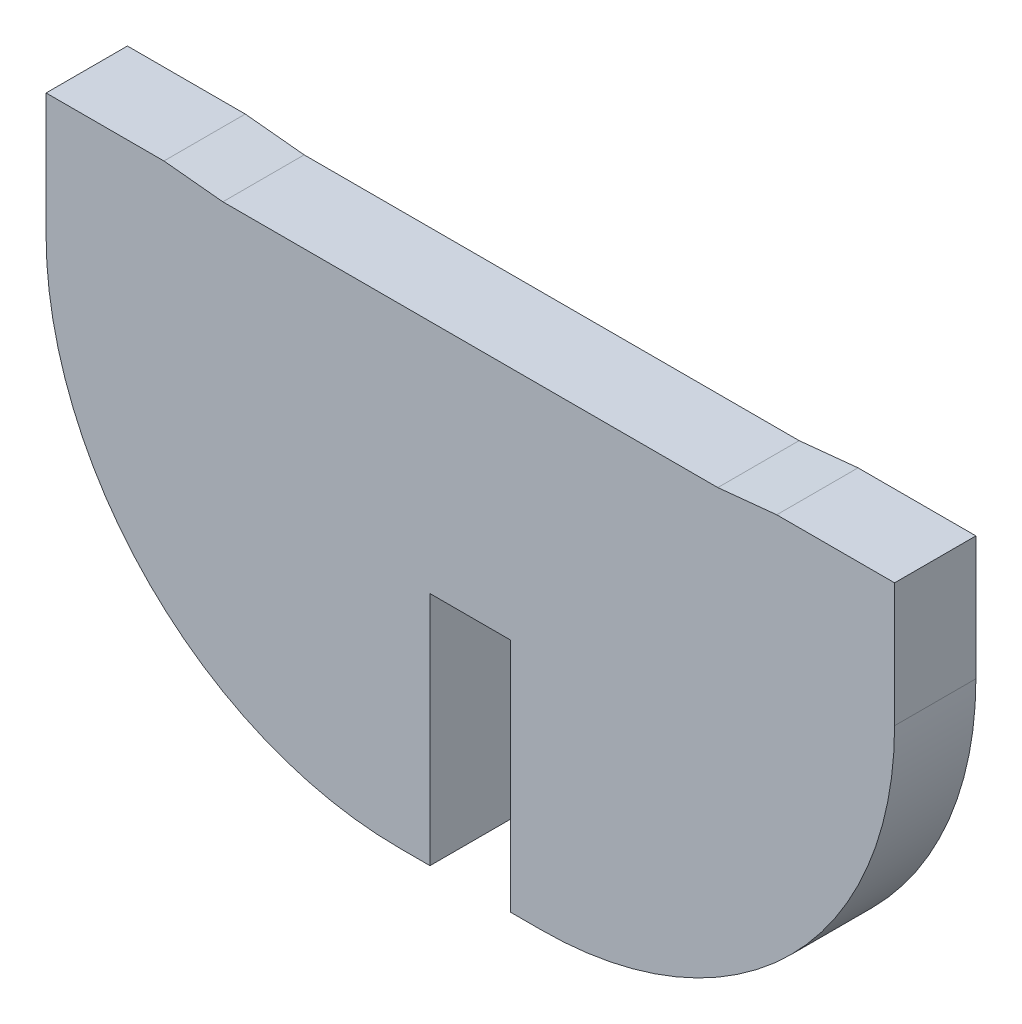
from build123d import *

# Parameters (mm, degrees)
SKETCH1_W           = 72
SKETCH1_H           = 40
BOSS_EXTRUDE1_DEPTH = 6.9
SKETCH2_W           = 6.85
SKETCH2_H           = 40
CUT_EXTRUDE1_DEPTH  = 7.9
FILLET1_R           = 30
BOSS_EXTRUDE2_DEPTH = 6.9


with BuildPart() as part:
    # Sketch1 → Boss-Extrude1 (new body)
    with BuildSketch(Plane.XY):
        Rectangle(SKETCH1_W, SKETCH1_H)
    extrude(amount=BOSS_EXTRUDE1_DEPTH)

    # Sketch2 → Cut-Extrude1 (cut, through all)
    with BuildSketch(Plane.XY.offset(6.9)):
        with Locations((0, -20)):
            Rectangle(SKETCH2_W, SKETCH2_H)
    extrude(amount=-CUT_EXTRUDE1_DEPTH, mode=Mode.SUBTRACT)

    # Fillet1
    fillet1_edges = [part.edges().sort_by_distance(p)[0] for p in [
        (36, -20, 3.45),
        (-36, -20, 3.45),
    ]]
    fillet(fillet1_edges, radius=FILLET1_R)

    # Sketch3 → Boss-Extrude2 (add)
    with BuildSketch(Plane.XY.offset(6.9)):
        Polygon((-36, 20), (-36, 20.5), (-26, 20.5), (-21, 20), (-21.749183803, 12.508161969), align=None)
    boss_extrude2 = extrude(amount=-BOSS_EXTRUDE2_DEPTH)

    # Mirror1: Boss-Extrude2 across plane
    add(boss_extrude2.mirror(Plane(origin=(0, 0, 0), x_dir=(0, 0, 1), z_dir=(1, 0, 0))))


solid = part.part
